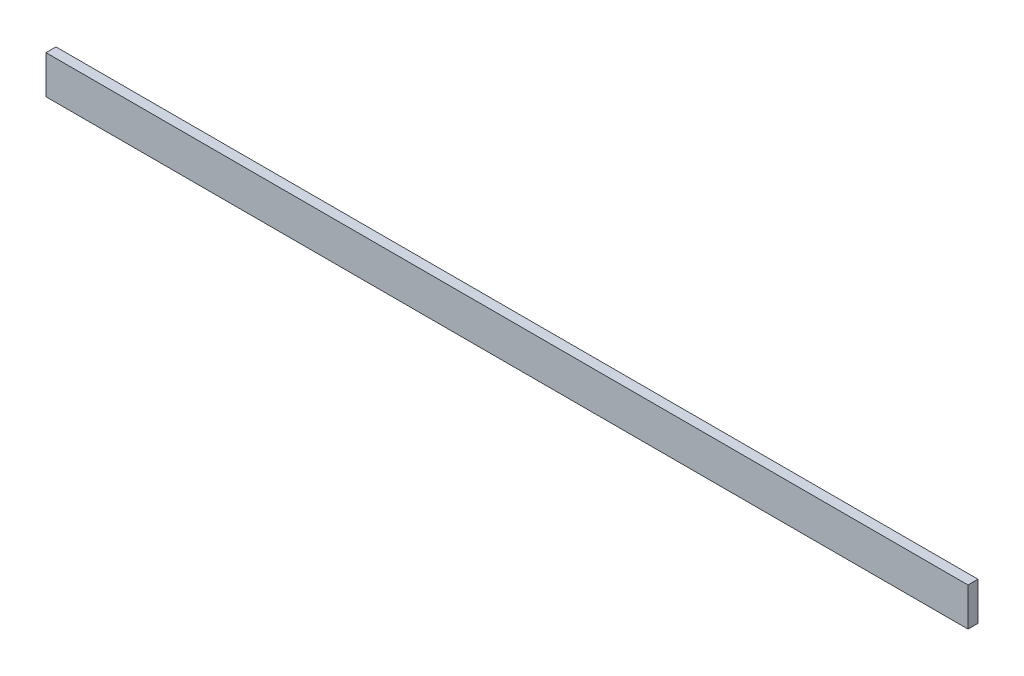
from build123d import *

# Parameters (mm, degrees)
SKETCH1_W           = 923.18559295
SKETCH1_H           = 38.292622135
BOSS_EXTRUDE1_DEPTH = 10


with BuildPart() as part:
    # Sketch1 → Boss-Extrude1 (new body)
    with BuildSketch(Plane.XY):
        with Locations((461.592796475, 19.146311068)):
            Rectangle(SKETCH1_W, SKETCH1_H)
    extrude(amount=BOSS_EXTRUDE1_DEPTH)


solid = part.part
